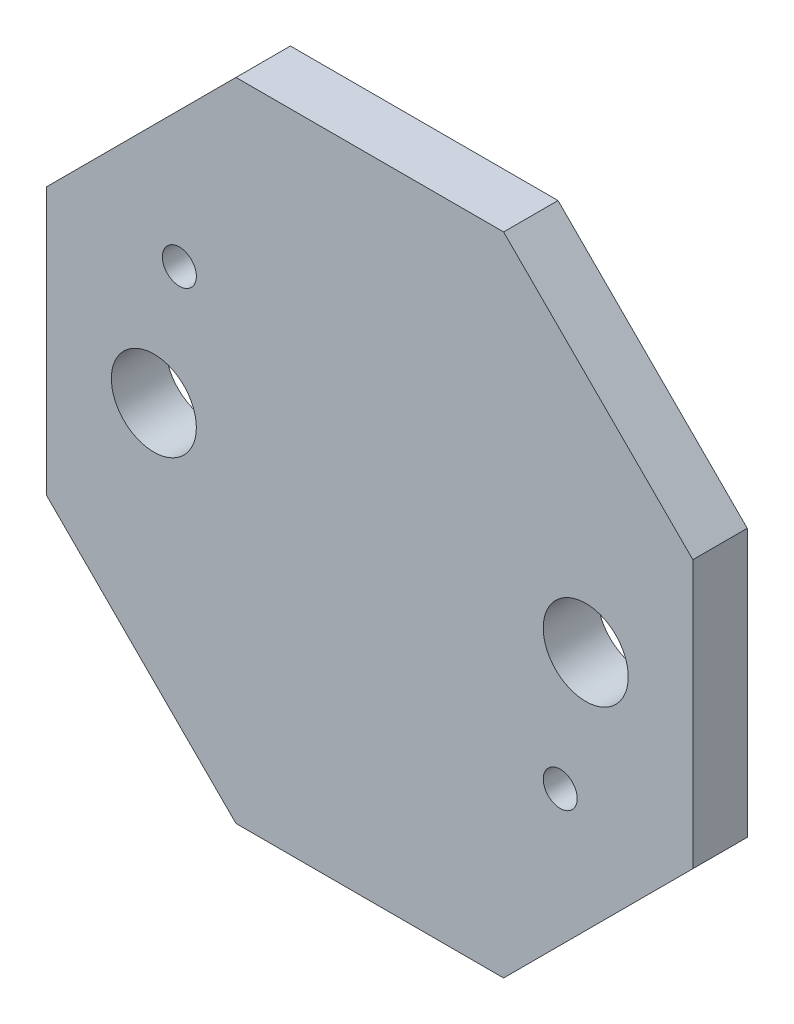
from build123d import *

# Parameters (mm, degrees)
SKETCH1_R           = 1.25
SKETCH1_R_2         = 0.5
BOSS_EXTRUDE1_DEPTH = 1.6


with BuildPart() as part:
    # Sketch1 → Boss-Extrude1 (new body)
    with BuildSketch(Plane.XY):
        Polygon((9.5, 3.935028843), (3.935028843, 9.5), (-3.935028843, 9.5), (-9.5, 3.935028843), (-9.5, -3.935028843), (-3.935028843, -9.5), (3.935028843, -9.5), (9.5, -3.935028843), align=None)
        with Locations((6.35, 0)):
            Circle(SKETCH1_R, mode=Mode.SUBTRACT)
        with Locations((5.6, -3.85)):
            Circle(SKETCH1_R_2, mode=Mode.SUBTRACT)
        with Locations((-6.35, 0)):
            Circle(SKETCH1_R, mode=Mode.SUBTRACT)
        with Locations((-5.6, 3.85)):
            Circle(SKETCH1_R_2, mode=Mode.SUBTRACT)
    extrude(amount=BOSS_EXTRUDE1_DEPTH)


solid = part.part
